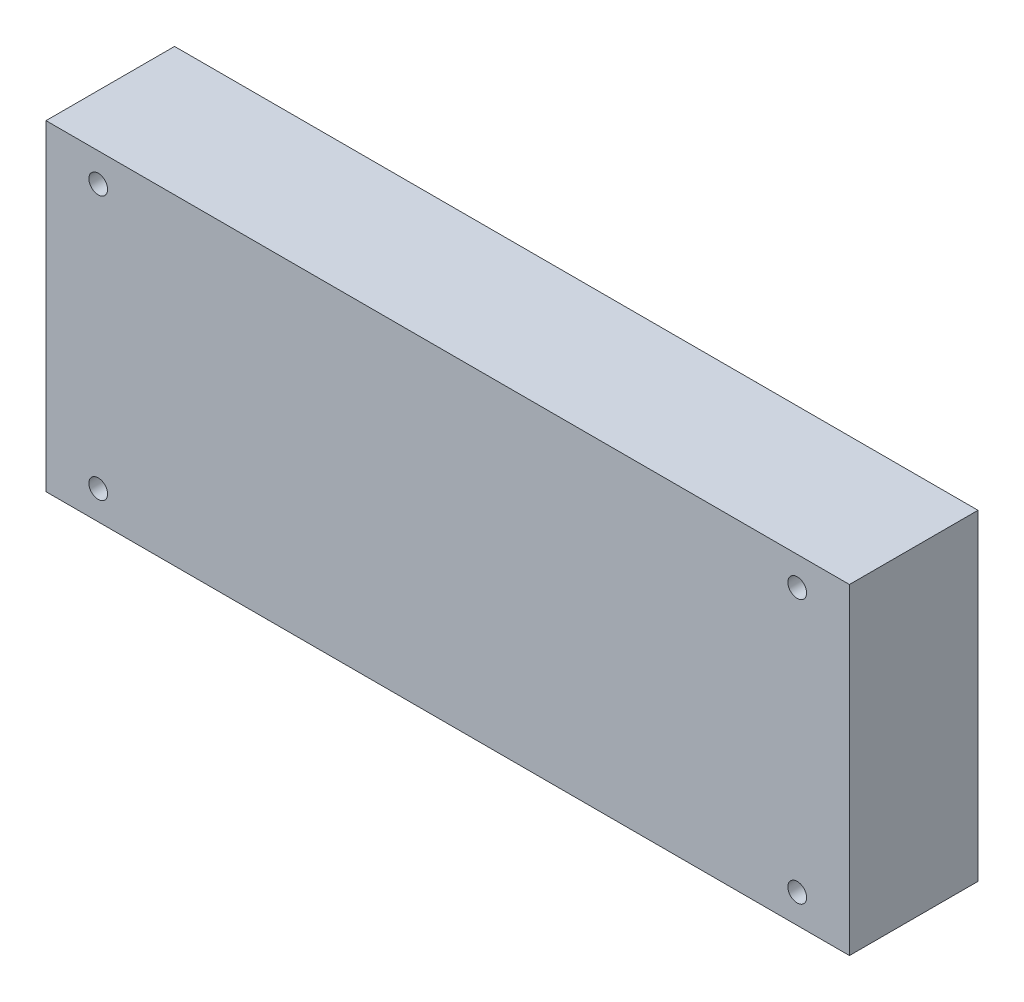
from build123d import *

# Parameters (mm, degrees)
SKETCH1_W               = 150
SKETCH1_H               = 60
SKETCH1_W_2             = 141
SKETCH1_H_2             = 52
BOSS_EXTRUDE1_DEPTH     = 20
SKETCH2_W               = 150
SKETCH2_H               = 60
BOSS_EXTRUDE2_DEPTH     = 4
SKETCH3_W               = 132
SKETCH3_H               = 17
CUT_EXTRUDE1_DEPTH      = 16
SKETCH4_R               = 1.75
CUT_EXTRUDE3_DEPTH      = 21
CUT_EXTRUDE3_DEPTH_BACK = 5
CUT_EXTRUDE4_START      = -20
SKETCH5_R               = 3
CUT_EXTRUDE4_DEPTH      = 20


with BuildPart() as part:
    # Sketch1 → Boss-Extrude1 (new body)
    with BuildSketch(Plane.XY):
        with Locations((75, 30)):
            Rectangle(SKETCH1_W, SKETCH1_H)
        with Locations((75, 30)):
            Rectangle(SKETCH1_W_2, SKETCH1_H_2, mode=Mode.SUBTRACT)
    extrude(amount=BOSS_EXTRUDE1_DEPTH)

    # Sketch2 → Boss-Extrude2 (add)
    with BuildSketch(Plane.XY.offset(20)):
        with Locations((75, 30)):
            Rectangle(SKETCH2_W, SKETCH2_H)
    extrude(amount=BOSS_EXTRUDE2_DEPTH)

    # Sketch3 → Cut-Extrude1 (cut)
    with BuildSketch(Plane.XZ):
        with Locations((75, 8.5)):
            Rectangle(SKETCH3_W, SKETCH3_H)
    extrude(amount=-CUT_EXTRUDE1_DEPTH, mode=Mode.SUBTRACT)

    # Sketch4 → Cut-Extrude3 (cut, two sides)
    with BuildSketch(Plane(origin=(0, 0, 20), x_dir=(-1, 0, 0), z_dir=(0, 0, -1))) as cut_extrude3_sk:
        with Locations((-140.25, 54.625)):
            Circle(SKETCH4_R)
        with Locations((-9.75, 54.625)):
            Circle(SKETCH4_R)
        with Locations((-9.75, 5.375)):
            Circle(SKETCH4_R)
        with Locations((-140.25, 5.375)):
            Circle(SKETCH4_R)
    extrude(amount=CUT_EXTRUDE3_DEPTH, mode=Mode.SUBTRACT)
    extrude(cut_extrude3_sk.sketch, amount=-CUT_EXTRUDE3_DEPTH_BACK, mode=Mode.SUBTRACT)

    # Sketch5 → Cut-Extrude4 (cut)
    with BuildSketch(Plane(origin=(0, 0, 0), x_dir=(-1, 0, 0), z_dir=(0, 0, -1)).offset(CUT_EXTRUDE4_START)):
        with Locations((-140.25, 5.375)):
            Circle(SKETCH5_R)
        with Locations((-9.75, 5.375)):
            Circle(SKETCH5_R)
        with Locations((-140.25, 54.625)):
            Circle(SKETCH5_R)
        with Locations((-9.75, 54.625)):
            Circle(SKETCH5_R)
    extrude(amount=CUT_EXTRUDE4_DEPTH, mode=Mode.SUBTRACT)


solid = part.part
